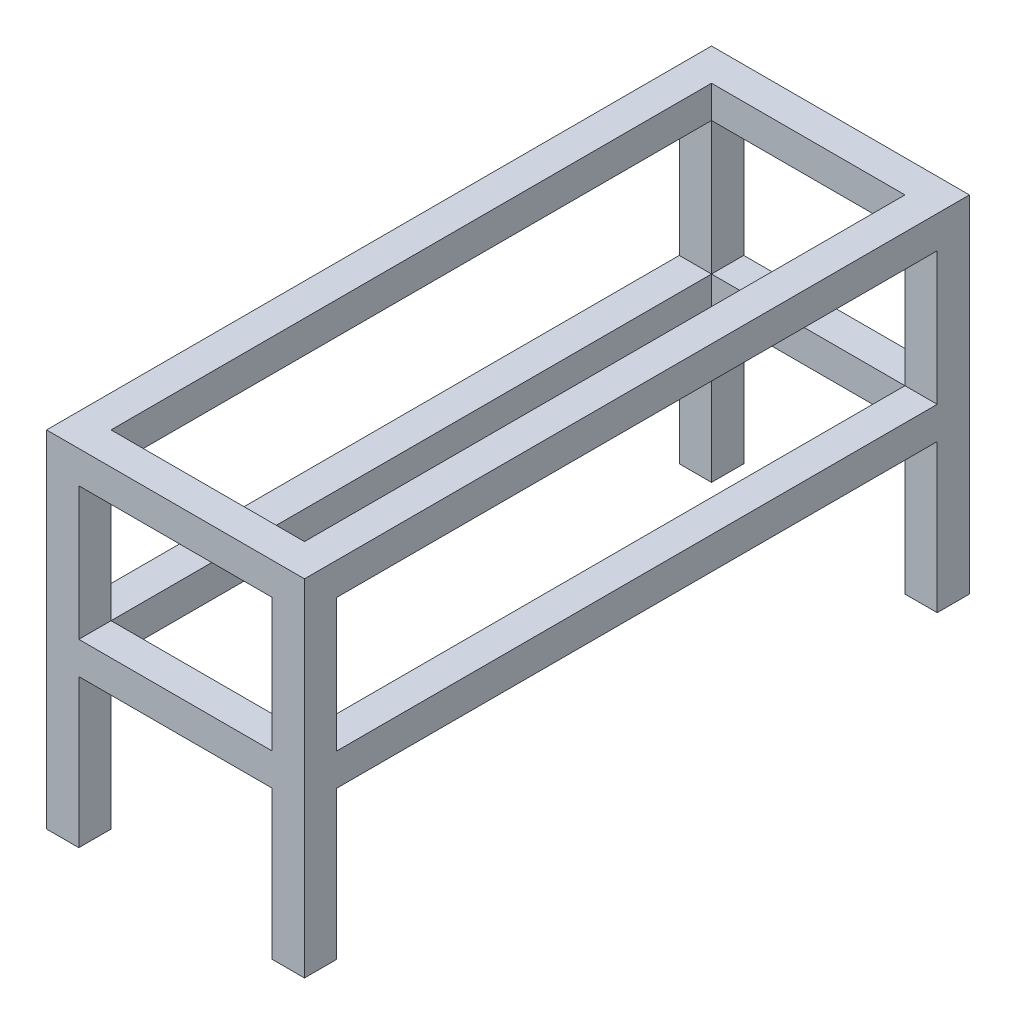
from build123d import *

# Parameters (mm, degrees)
SKETCH1_W           = 480
SKETCH1_H           = 330
BOSS_EXTRUDE1_DEPTH = 80
SKETCH2_W           = 80
SKETCH2_H           = 80
BOSS_EXTRUDE2_DEPTH = 745


with BuildPart() as part:
    # Sketch1 → Boss-Extrude1 (new body)
    with BuildSketch(Plane.XY):
        Polygon((640, 0), (0, 0), (0, -857.8016), (80, -857.8016), (80, -490), (560, -490), (560, -857.8016), (640, -857.8016), align=None)
        with Locations((320, -245)):
            Rectangle(SKETCH1_W, SKETCH1_H, mode=Mode.SUBTRACT)
    boss_extrude1 = extrude(amount=-BOSS_EXTRUDE1_DEPTH)

    # Sketch2 → Boss-Extrude2 (add)
    with BuildSketch(Plane(origin=(0, 0, -80), x_dir=(-1, 0, 0), z_dir=(0, 0, -1))):
        with Locations((-600, -40)):
            Rectangle(SKETCH2_W, SKETCH2_H)
        with Locations((-40, -40)):
            Rectangle(SKETCH2_W, SKETCH2_H)
        with Locations((-600, -450)):
            Rectangle(SKETCH2_W, SKETCH2_H)
        with Locations((-40, -450)):
            Rectangle(SKETCH2_W, SKETCH2_H)
    boss_extrude2 = extrude(amount=BOSS_EXTRUDE2_DEPTH)

    # Mirror2: Boss-Extrude2 across plane
    add(boss_extrude2.mirror(Plane.XY.offset(-825)))

    # Mirror3: Boss-Extrude1 across plane
    add(boss_extrude1.mirror(Plane.XY.offset(-825)))


solid = part.part
